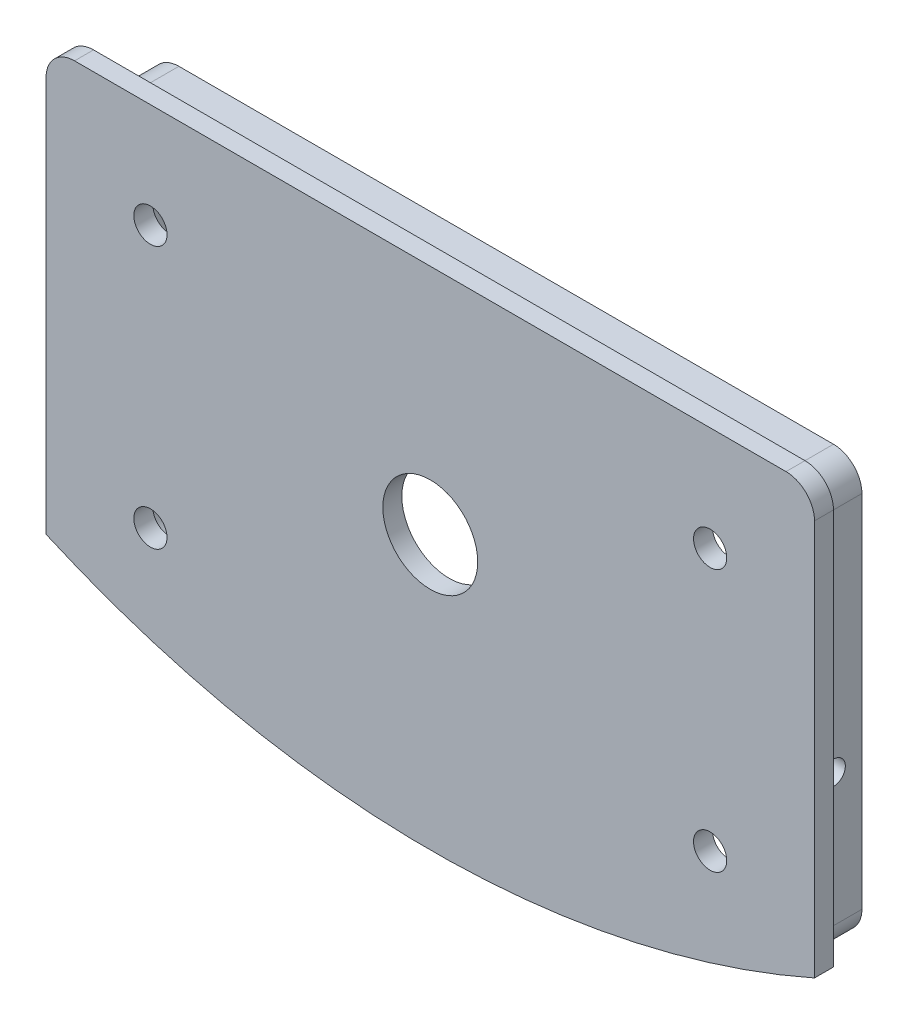
from build123d import *

# Parameters (mm, degrees)
DODANIE_WYCI_GNI_CIE1_DEPTH = 6
DODANIE_WYCI_GNI_CIE2_DEPTH = 2
SKORUPA1_T                  = -2
SZKIC3_R                    = 1.7499999999999998
SZKIC3_R_2                  = 1.7500000000000004
SZKIC3_R_3                  = 5
WYTNIJ_WYCI_GNI_CIE1_DEPTH  = 2
ZAOKR_GLENIE1_R             = 3
ZAOKR_GLENIE2_R             = 2
WYTNIJ_WYCI_GNI_CIE2_REACH  = 85.53
SZKIC4_R                    = 1.2500000000000009


with BuildPart() as part:
    # Szkic1 → Dodanie-wyciągnięcie1 (new body)
    with BuildSketch(Plane.XY):
        with BuildLine():
            Line((-37.5, 21.499999999999993), (37.5, 21.499999999999993))
            Line((37.5, 21.499999999999993), (37.5, -21.500000000000004))
            ThreePointArc((37.5, -21.500000000000004), (1.312e-14, -28.797518911304223), (-37.49999999999999, -21.500000000000004))
            Line((-37.49999999999999, -21.500000000000004), (-37.5, 21.499999999999993))
        make_face()
    extrude(amount=DODANIE_WYCI_GNI_CIE1_DEPTH)

    # Szkic2 → Dodanie-wyciągnięcie2 (add)
    with BuildSketch(Plane.XY.offset(6)):
        with BuildLine():
            Line((-40.5, -20.229187385635353), (-40.5, 21.49999999999997))
            ThreePointArc((-40.5, 21.49999999999997), (-39.62132034355964, 23.62132034355963), (-37.49999999999998, 24.49999999999999))
            Line((-37.49999999999998, 24.49999999999999), (37.49999999999998, 24.49999999999999))
            ThreePointArc((37.49999999999998, 24.49999999999999), (39.621320343559645, 23.621320343559635), (40.5, 21.49999999999997))
            Line((40.5, 21.49999999999997), (40.50000000000001, -20.229187385635377))
            ThreePointArc((40.50000000000001, -20.229187385635377), (-9.09e-15, -28.797518911304223), (-40.5, -20.229187385635353))
        make_face()
    extrude(amount=DODANIE_WYCI_GNI_CIE2_DEPTH)

    # Skorupa1
    skorupa1_openings = [part.faces().sort_by_distance(p)[0] for p in [
        (0, -2.499693037, 0),
    ]]
    offset(amount=SKORUPA1_T, openings=skorupa1_openings, kind=Kind.INTERSECTION)

    # Szkic3 → Wytnij-wyciągnięcie1 (cut)
    with BuildSketch(Plane(origin=(0, 0, 6), x_dir=(-1, 0, 0), z_dir=(0, 0, -1))):
        with Locations((-29.5, 13.49999999999999)):
            Circle(SZKIC3_R)
        with Locations((29.5, 13.49999999999999)):
            Circle(SZKIC3_R)
        with Locations((29.5, -14.141648443529768)):
            Circle(SZKIC3_R_2)
        with Locations((-29.5, -14.141648443529768)):
            Circle(SZKIC3_R_2)
        Circle(SZKIC3_R_3)
    extrude(amount=-WYTNIJ_WYCI_GNI_CIE1_DEPTH, mode=Mode.SUBTRACT)

    # Zaokrąglenie1
    zaokr_glenie1_edges = [part.edges().sort_by_distance(p)[0] for p in [
        (-35.5, -20.14164844352976, 3),
        (35.5, -20.14164844352979, 3),
        (35.5, 19.499999999999993, 3),
        (-35.5, 19.499999999999993, 3),
        (-37.499999999999986, -21.5, 3),
        (-37.5, 21.499999999999993, 3),
        (37.5, 21.499999999999993, 3),
        (37.5, -21.499999999999993, 3),
    ]]
    fillet(zaokr_glenie1_edges, radius=ZAOKR_GLENIE1_R)

    # Zaokrąglenie2
    zaokr_glenie2_edges = [part.edges().sort_by_distance(p)[0] for p in [
        (-35.5, -0.7826871340449166, 6),
        (1.421e-14, -26.797518911304223, 6),
        (0, 19.499999999999993, 6),
        (35.5, -0.7826871340449308, 6),
        (-34.621320343559645, 18.621320343559635, 6),
        (34.621320343559645, 18.621320343559635, 6),
        (34.95753406572738, -19.785992272119067, 6),
        (-34.95753406572737, -19.785992272119046, 6),
    ]]
    fillet(zaokr_glenie2_edges, radius=ZAOKR_GLENIE2_R)

    # Wytnij-wyciągnięcie2: up to this face of the body (flat: up to its plane)
    wytnij_wyci_gni_cie2_end = Plane(part.part.faces().sort_by_distance((37.5, -0.477420367, 3))[0])
    # Szkic4 → Wytnij-wyciągnięcie2 (cut, up to the picked face)
    with BuildSketch(Plane.ZY.offset(37.5), mode=Mode.PRIVATE) as wytnij_wyci_gni_cie2_sk1:
        with Locations(Location((2.999999999998171, -5.500000000000033, 0), (0, 0, 323.130102354))):
            Circle(SZKIC4_R)
    wytnij_wyci_gni_cie2_tool1 = split(extrude(wytnij_wyci_gni_cie2_sk1.sketch, amount=-WYTNIJ_WYCI_GNI_CIE2_REACH, mode=Mode.PRIVATE), bisect_by=wytnij_wyci_gni_cie2_end, keep=Keep.BOTH, mode=Mode.PRIVATE)
    add(wytnij_wyci_gni_cie2_tool1.solids().sort_by(Axis((-37.5, -5.5, 3), (1, 1.6e-16, 0)))[0], mode=Mode.SUBTRACT)


solid = part.part
